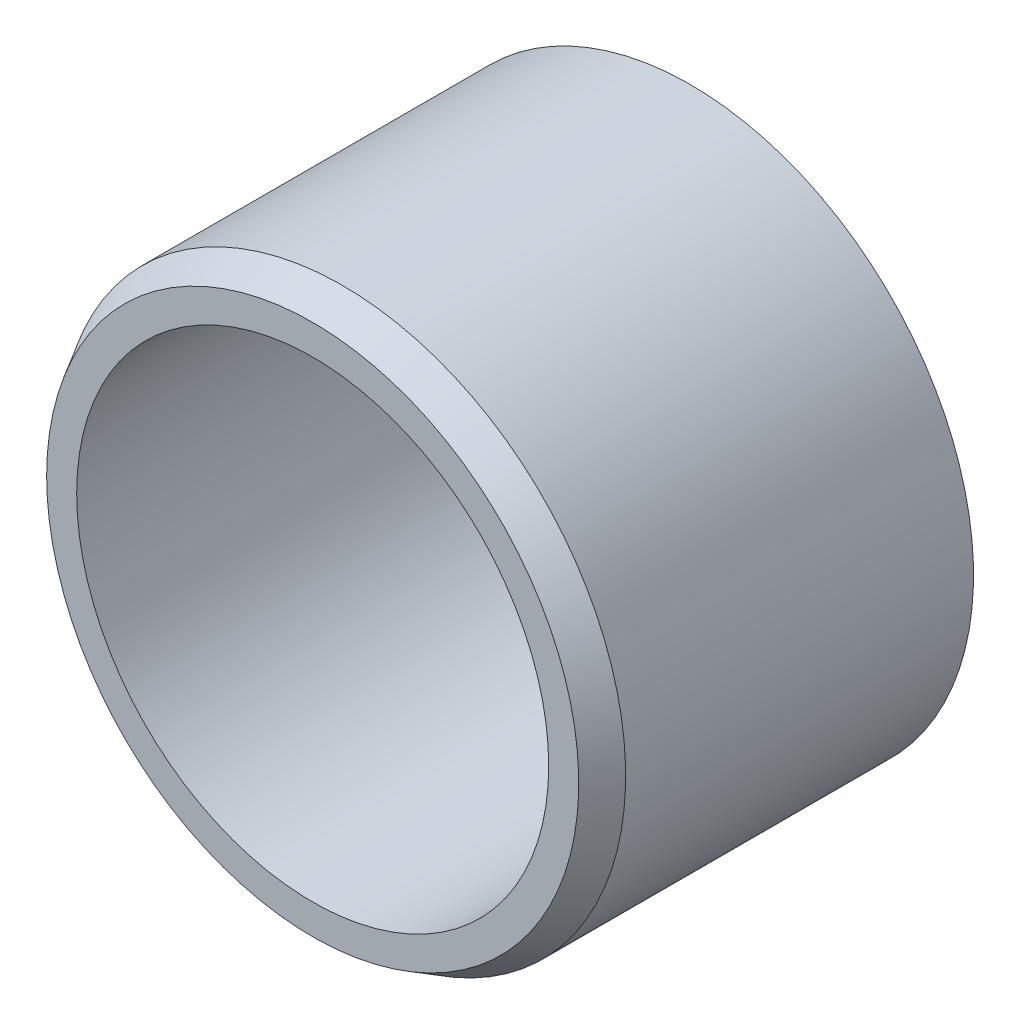
from build123d import *


with BuildPart() as part:
    # Sketch1 → Revolve1 (revolve)
    with BuildSketch(Plane.XZ):
        Polygon((4.473824865, 6.35), (3.96875, 6.35), (3.96875, 0.5), (4.257425135, 0), (4.7625, 0), (4.7625, 5.85), align=None)
    revolve(axis=Axis((0, 0, 6.35), (0, 0, -1)))


solid = part.part
